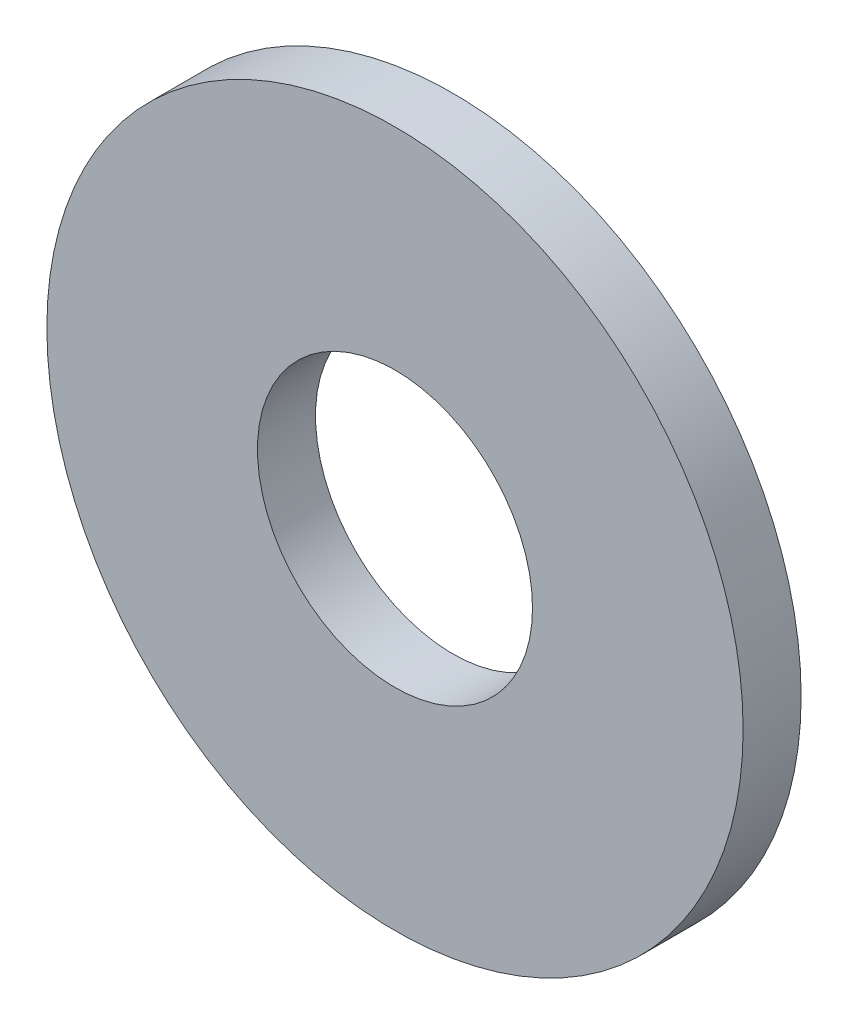
from build123d import *

# Parameters (mm, degrees)
SKETCH2_R           = 38.1
BOSS_EXTRUDE1_DEPTH = 6.35
SKETCH3_R           = 15.05
CUT_EXTRUDE1_DEPTH  = 6.35


with BuildPart() as part:
    # Sketch2 → Boss-Extrude1 (new body)
    with BuildSketch(Plane.XY):
        Circle(SKETCH2_R)
    extrude(amount=BOSS_EXTRUDE1_DEPTH)

    # Sketch3 → Cut-Extrude1 (cut)
    with BuildSketch(Plane.XY.offset(6.35)):
        Circle(SKETCH3_R)
    extrude(amount=-CUT_EXTRUDE1_DEPTH, mode=Mode.SUBTRACT)


solid = part.part
